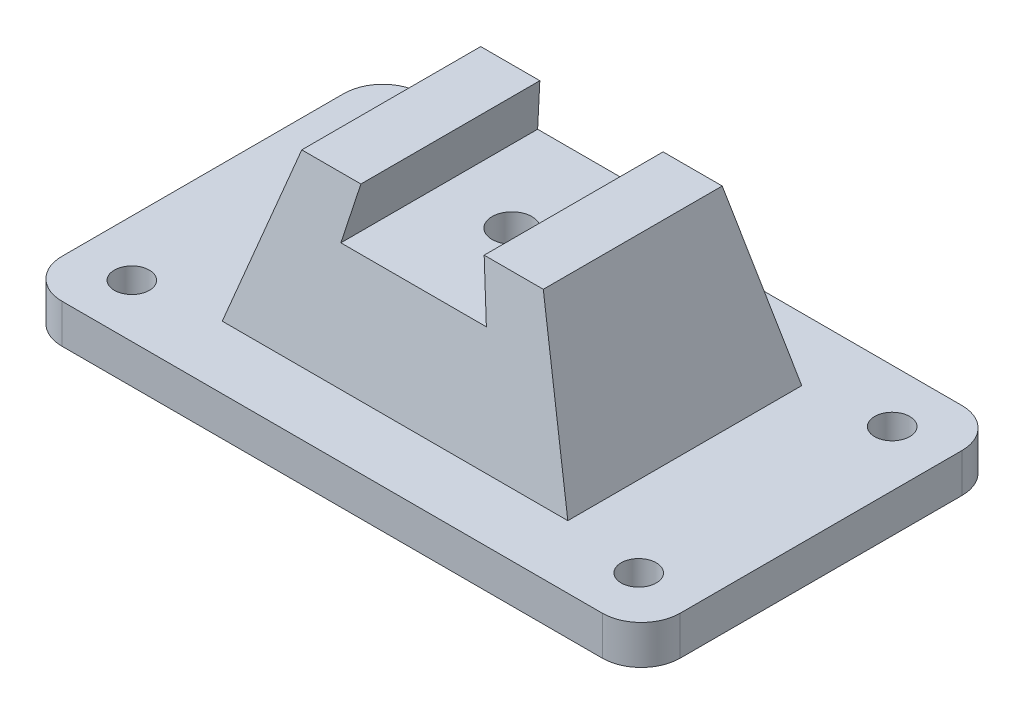
from build123d import *

# Parameters (mm, degrees)
AUFSATZ_LINEAR_AUSTRAGEN1_DEPTH      = 10
AUFSATZ_LINEAR_AUSTRAGEN2_DEPTH      = 30
SCHNITT_LINEAR_AUSTRAGEN1_DEPTH      = 80.274901172
SCHNITT_LINEAR_AUSTRAGEN1_DEPTH_BACK = 80.274901172
SCHNITT_LINEAR_AUSTRAGEN2_DEPTH      = 47.124758374
SCHNITT_LINEAR_AUSTRAGEN2_DEPTH_BACK = 47.124758374
DURCHGANGSLOCH_F_R_M81_D             = 9
M12_GEWINDEBOHRUNG1_D                = 10.2


with BuildPart() as part:
    # Skizze1 → Aufsatz-Linear austragen1 (new body)
    with BuildSketch(Plane(origin=(0, 0, 0), x_dir=(1, 0, 0), z_dir=(0, 1, 0))):
        with BuildLine():
            Line((-69.274901172, 46.124758374), (69.274901172, 46.124758374))
            ThreePointArc((69.274901172, 46.124758374), (76.345968983, 43.195826186), (79.274901172, 36.124758374))
            Line((79.274901172, 36.124758374), (79.274901172, -36.124758374))
            ThreePointArc((79.274901172, -36.124758374), (76.345968983, -43.195826186), (69.274901172, -46.124758374))
            Line((69.274901172, -46.124758374), (-69.274901172, -46.124758374))
            ThreePointArc((-69.274901172, -46.124758374), (-76.345968983, -43.195826186), (-79.274901172, -36.124758374))
            Line((-79.274901172, -36.124758374), (-79.274901172, 36.124758374))
            ThreePointArc((-79.274901172, 36.124758374), (-76.345968983, 43.195826186), (-69.274901172, 46.124758374))
        make_face()
    extrude(amount=AUFSATZ_LINEAR_AUSTRAGEN1_DEPTH)

    # Skizze2 → Aufsatz-Linear austragen2 (add, symmetric)
    with BuildSketch(Plane.XY):
        Polygon((-30.968636567, 51.19380308), (-44.314952745, 10), (44.314952745, 10), (30.968636567, 51.19380308), align=None)
    extrude(amount=AUFSATZ_LINEAR_AUSTRAGEN2_DEPTH, both=True)

    # Skizze3 → Schnitt-Linear austragen1 (cut, two sides)
    with BuildSketch(Plane(origin=(0, 0, 0), x_dir=(0, 0, -1), z_dir=(1, 0, 0))) as schnitt_linear_austragen1_sk:
        Polygon((-30, 10), (-22.945404255, 51.19380308), (-30, 51.19380308), align=None)
        Polygon((30, 51.19380308), (30, 10), (22.945404255, 51.19380308), align=None)
    extrude(amount=SCHNITT_LINEAR_AUSTRAGEN1_DEPTH, mode=Mode.SUBTRACT)
    extrude(schnitt_linear_austragen1_sk.sketch, amount=-SCHNITT_LINEAR_AUSTRAGEN1_DEPTH_BACK, mode=Mode.SUBTRACT)

    # Skizze4 → Schnitt-Linear austragen2 (cut, two sides)
    with BuildSketch(Plane.XY) as schnitt_linear_austragen2_sk:
        Polygon((-15.808257997, 51.19380308), (-18.658927471, 37.841822693), (18.658927471, 37.841822693), (15.808257997, 51.19380308), align=None)
    extrude(amount=SCHNITT_LINEAR_AUSTRAGEN2_DEPTH, mode=Mode.SUBTRACT)
    extrude(schnitt_linear_austragen2_sk.sketch, amount=-SCHNITT_LINEAR_AUSTRAGEN2_DEPTH_BACK, mode=Mode.SUBTRACT)

    # Durchgangsloch für M81 (through all)
    with Locations(Plane(origin=(0, 10, 0), x_dir=(1, 0, 0), z_dir=(0, 1, 0))):
        with Locations((-65, 32.5), (65, 32.5), (65, -32.5), (-65, -32.5)):
            Hole(DURCHGANGSLOCH_F_R_M81_D / 2)

    # M12 Gewindebohrung1 (through all)
    with Locations(Plane(origin=(0, 37.841822693, 0), x_dir=(1, 0, 0), z_dir=(0, 1, 0))):
        with Locations((0, 0)):
            Hole(M12_GEWINDEBOHRUNG1_D / 2)


solid = part.part
